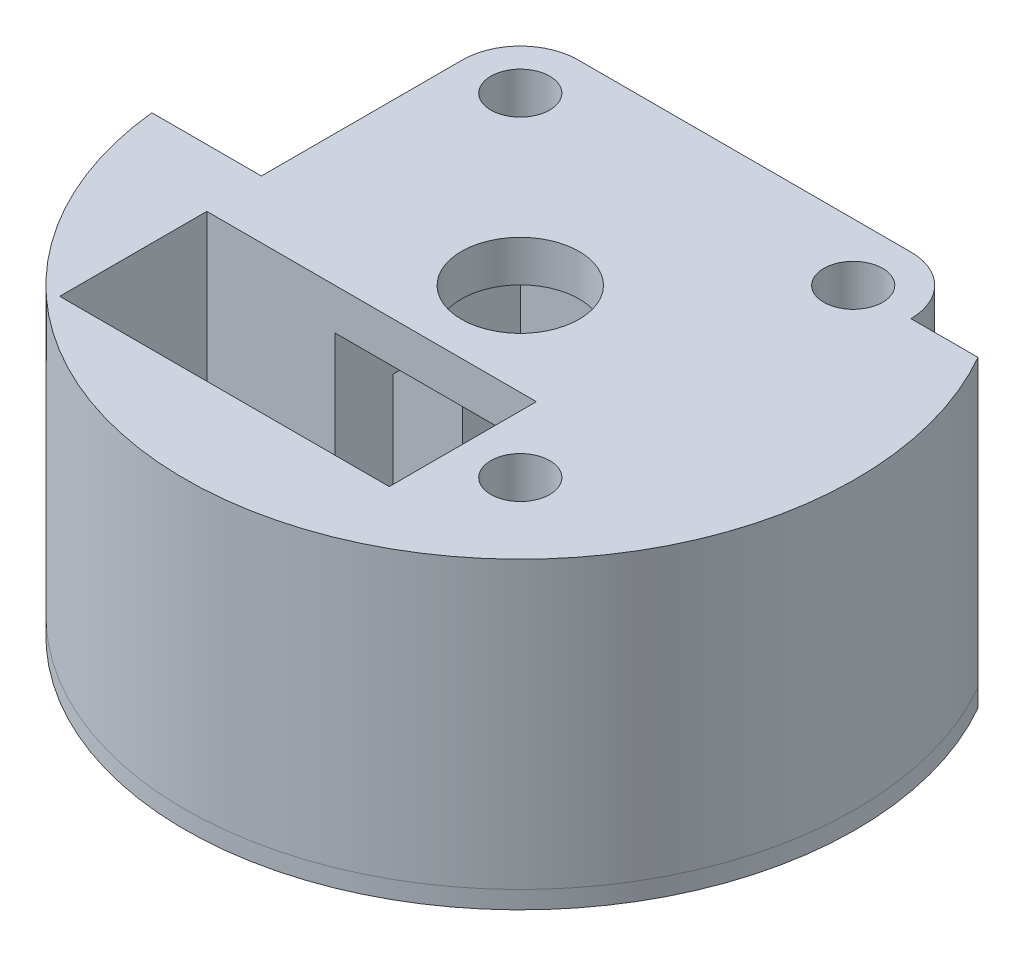
from build123d import *
from build123d.topology import SkipClean

# Parameters (mm, degrees)
SKETCH2_R               = 3.175
BOSS_EXTRUDE1_DEPTH     = 1.905
SKETCH3_R               = 3.175
BOSS_EXTRUDE2_DEPTH     = 19.431
SKETCH4_R               = 3.175
BOSS_EXTRUDE3_DEPTH     = 6.985
SKETCH5_R               = 6.35
SKETCH5_R_2             = 3.175
BOSS_EXTRUDE4_DEPTH     = 4.445
CUT_EXTRUDE1_DEPTH      = 78.648267988
CUT_EXTRUDE1_DEPTH_BACK = 5.7
SKETCH6_R               = 1.95


with BuildPart() as part:
    # Sketch2 → Boss-Extrude1 (new body)
    with BuildSketch(Plane(origin=(0, 0, 0), x_dir=(1, 0, 0), z_dir=(0, 1, 0))):
        with BuildLine():
            Line((-24.183512242, 17.960512242), (-24.183512242, 3.75))
            Line((-24.183512242, 3.75), (-10, 3.75))
            Line((-10, 3.75), (-10, 10))
            Line((-10, 10), (30, 10))
            Line((30, 10), (30, -10))
            Line((30, -10), (11.737512242, -10))
            Line((11.737512242, -10), (10, -10))
            Line((10, -10), (0, -10))
            Line((0, -10), (-10, -10))
            Line((-10, -10), (-10, -3.75))
            Line((-10, -3.75), (-24.183512242, -3.75))
            Line((-24.183512242, -3.75), (-36.000215624, -3.75))
            ThreePointArc((-36.000215624, -3.75), (11.093733439, -34.452969442), (31.4244813, 17.960512242))
            Line((31.4244813, 17.960512242), (24.183512242, 17.960512242))
            ThreePointArc((24.183512242, 17.960512242), (22.360837741, 22.360837741), (17.960512242, 24.183512242))
            Line((17.960512242, 24.183512242), (-17.960512242, 24.183512242))
            ThreePointArc((-17.960512242, 24.183512242), (-22.360837741, 22.360837741), (-24.183512242, 17.960512242))
        make_face()
        with Locations(Location((-17.960512242, 17.960512242, 0), (0, 0, 90))):
            Circle(SKETCH2_R, mode=Mode.SUBTRACT)
        with Locations(Location((17.960512242, 17.960512242, 0), (0, 0, 90))):
            Circle(SKETCH2_R, mode=Mode.SUBTRACT)
        with Locations(Location((17.960512242, -17.960512242, 0), (0, 0, 90))):
            Circle(SKETCH2_R, mode=Mode.SUBTRACT)
    extrude(amount=BOSS_EXTRUDE1_DEPTH)


with BuildPart() as body_2:
    # Sketch3 → Boss-Extrude2 (new body)
    with BuildSketch(Plane(origin=(0, 1.905, 0), x_dir=(1, 0, 0), z_dir=(0, 1, 0))):
        with BuildLine():
            Line((-23.822487758, -25.875), (-23.822487758, -10))
            Line((-23.822487758, -10), (-17.960512242, -10))
            Line((-17.960512242, -10), (-10, -10))
            Line((-10, -10), (-10, -3.75))
            Line((-10, -3.75), (-36.000215624, -3.75))
            ThreePointArc((-36.000215624, -3.75), (11.093733439, -34.452969442), (31.4244813, 17.960512242))
            Line((31.4244813, 17.960512242), (24.183512242, 17.960512242))
            ThreePointArc((24.183512242, 17.960512242), (22.360837741, 22.360837741), (17.960512242, 24.183512242))
            Line((17.960512242, 24.183512242), (-17.960512242, 24.183512242))
            ThreePointArc((-17.960512242, 24.183512242), (-22.360837741, 22.360837741), (-24.183512242, 17.960512242))
            Line((-24.183512242, 17.960512242), (-24.183512242, 3.75))
            Line((-24.183512242, 3.75), (-10, 3.75))
            Line((-10, 3.75), (-10, 10))
            Line((-10, 10), (30, 10))
            Line((30, 10), (30, -10))
            Line((30, -10), (11.737512242, -10))
            Line((11.737512242, -10), (11.737512242, -11.737512242))
            Line((11.737512242, -11.737512242), (11.737512242, -17.960512242))
            Line((11.737512242, -17.960512242), (11.737512242, -25.875))
            Line((11.737512242, -25.875), (-23.822487758, -25.875))
        make_face()
        with Locations(Location((17.960512242, -17.960512242, 0), (0, 0, 90))):
            Circle(SKETCH3_R, mode=Mode.SUBTRACT)
        with Locations(Location((-17.960512242, 17.960512242, 0), (0, 0, 90))):
            Circle(SKETCH3_R, mode=Mode.SUBTRACT)
        with Locations(Location((17.960512242, 17.960512242, 0), (0, 0, 90))):
            Circle(SKETCH3_R, mode=Mode.SUBTRACT)
    extrude(amount=BOSS_EXTRUDE2_DEPTH)

    # Sketch4 → Boss-Extrude3 (add)
    with SkipClean():  # the faces are left unmerged after this step: merging them gives an invalid solid
        with BuildSketch(Plane(origin=(0, 21.336, 0), x_dir=(1, 0, 0), z_dir=(0, 1, 0))):
            with BuildLine():
                Line((-24.183512242, -3.75), (-24.183512242, 3.75))
                Line((-24.183512242, 3.75), (-24.183512242, 17.960512242))
                ThreePointArc((-24.183512242, 17.960512242), (-22.360837741, 22.360837741), (-17.960512242, 24.183512242))
                Line((-17.960512242, 24.183512242), (17.960512242, 24.183512242))
                ThreePointArc((17.960512242, 24.183512242), (22.360837741, 22.360837741), (24.183512242, 17.960512242))
                Line((24.183512242, 17.960512242), (31.4244813, 17.960512242))
                ThreePointArc((31.4244813, 17.960512242), (11.093733439, -34.452969442), (-36.000215624, -3.75))
                Line((-36.000215624, -3.75), (-24.183512242, -3.75))
            make_face()
            with Locations(Location((17.960512242, -17.960512242, 0), (0, 0, 90))):
                Circle(SKETCH4_R, mode=Mode.SUBTRACT)
            with Locations(Location((17.960512242, 17.960512242, 0), (0, 0, 90))):
                Circle(SKETCH4_R, mode=Mode.SUBTRACT)
            with Locations(Location((-17.960512242, 17.960512242, 0), (0, 0, 90))):
                Circle(SKETCH4_R, mode=Mode.SUBTRACT)
            Polygon((-10, -3.75), (-10, 0), (-10, 3.75), (-10, 10), (30, 10), (30, -10), (11.737512242, -10), (11.737512242, -25.875), (-23.822487758, -25.875), (-23.822487758, -10), (-10, -10), align=None, mode=Mode.SUBTRACT)
        extrude(amount=BOSS_EXTRUDE3_DEPTH)

    # Sketch5 → Boss-Extrude4 (add)
    with SkipClean():  # the faces are left unmerged after this step: merging them gives an invalid solid
        with BuildSketch(Plane(origin=(0, 28.321, 0), x_dir=(1, 0, 0), z_dir=(0, 1, 0))):
            with BuildLine():
                Line((-24.183512242, 17.960512242), (-24.183512242, -3.75))
                Line((-24.183512242, -3.75), (-36.000215624, -3.75))
                ThreePointArc((-36.000215624, -3.75), (11.093733439, -34.452969442), (31.4244813, 17.960512242))
                Line((31.4244813, 17.960512242), (24.183512242, 17.960512242))
                ThreePointArc((24.183512242, 17.960512242), (22.360837741, 22.360837741), (17.960512242, 24.183512242))
                Line((17.960512242, 24.183512242), (-17.960512242, 24.183512242))
                ThreePointArc((-17.960512242, 24.183512242), (-22.360837741, 22.360837741), (-24.183512242, 17.960512242))
            make_face()
            with Locations(Location((0, 0, 0), (0, 0, 270))):
                Circle(SKETCH5_R, mode=Mode.SUBTRACT)
            with Locations(Location((17.960512242, -17.960512242, 0), (0, 0, 90))):
                Circle(SKETCH5_R_2, mode=Mode.SUBTRACT)
            with Locations(Location((17.960512242, 17.960512242, 0), (0, 0, 90))):
                Circle(SKETCH5_R_2, mode=Mode.SUBTRACT)
            with Locations(Location((-17.960512242, 17.960512242, 0), (0, 0, 90))):
                Circle(SKETCH5_R_2, mode=Mode.SUBTRACT)
            Polygon((11.737512242, -25.875), (-23.822487758, -25.875), (-23.822487758, -10), (-17.960512242, -10), (-10, -10), (0, -10), (10, -10), (11.737512242, -10), (11.737512242, -11.737512242), (11.737512242, -17.960512242), align=None, mode=Mode.SUBTRACT)
        extrude(amount=BOSS_EXTRUDE4_DEPTH)

    # Sketch6 → Cut-Extrude1 (cut, two sides: drawn at the far end of the back side and taken through both)
    with SkipClean():  # the faces are left unmerged after this step: merging them gives an invalid solid
        with BuildSketch(Plane(origin=(0, 0, -24.183512242), x_dir=(-1, 0, 0), z_dir=(0, 0, -1)).offset(-CUT_EXTRUDE1_DEPTH_BACK)):
            with Locations(Location((-10.9855, 27.711479032, 0), (0, 0, 180))):
                Circle(SKETCH6_R)
            with Locations(Location((10.9855, 27.711479032, 0), (0, 0, 180))):
                Circle(SKETCH6_R)
            with Locations(Location((10.9855, 12.725479032, 0), (0, 0, 180))):
                Circle(SKETCH6_R)
            with Locations(Location((-10.9855, 12.725479032, 0), (0, 0, 180))):
                Circle(SKETCH6_R)
        extrude(amount=CUT_EXTRUDE1_DEPTH + CUT_EXTRUDE1_DEPTH_BACK, mode=Mode.SUBTRACT)


solid = Compound([part.part, body_2.part])
